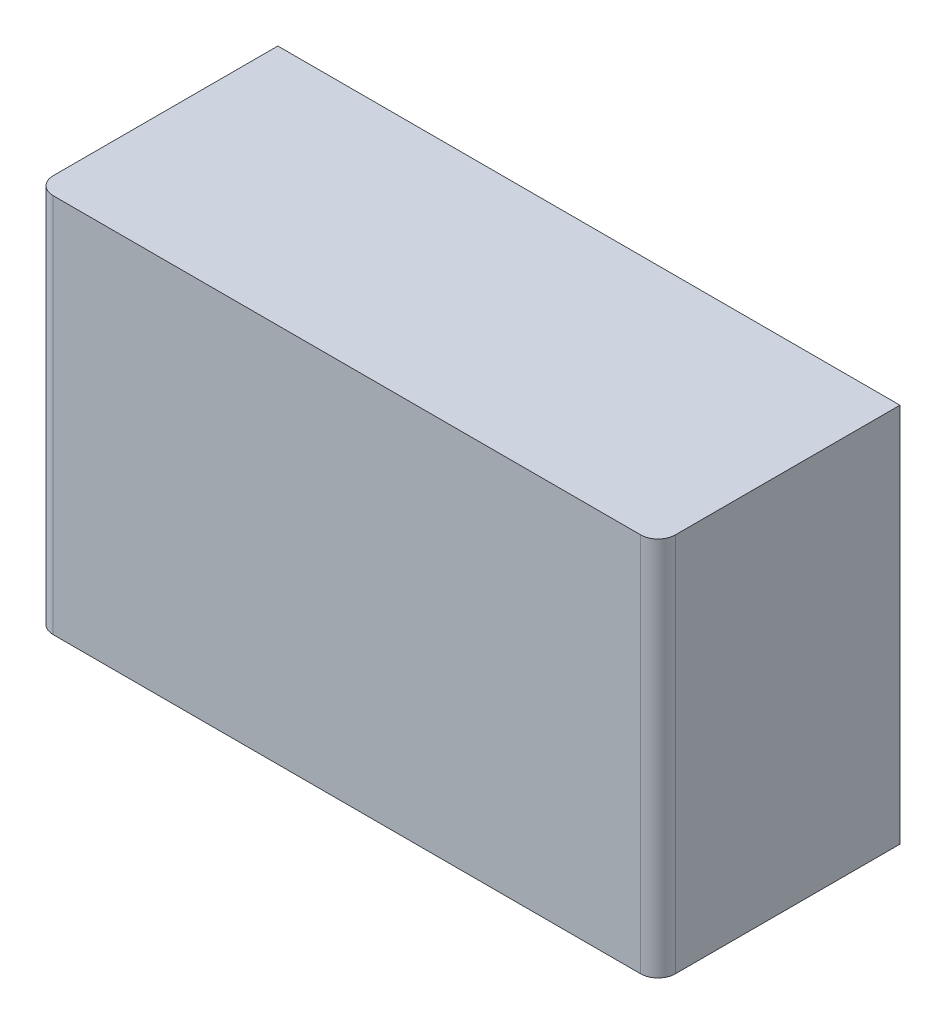
from build123d import *

# Parameters (mm, degrees)
SKETCH1_W           = 914.4
SKETCH1_H           = 355.6
BOSS_EXTRUDE1_DEPTH = 558.8
FILLET1_R           = 25.4


with BuildPart() as part:
    # Sketch1 → Boss-Extrude1 (new body)
    with BuildSketch(Plane(origin=(0, 0, 0), x_dir=(1, 0, 0), z_dir=(0, 1, 0))):
        Rectangle(SKETCH1_W, SKETCH1_H)
    extrude(amount=BOSS_EXTRUDE1_DEPTH)

    # Fillet1
    fillet1_edges = [part.edges().sort_by_distance(p)[0] for p in [
        (457.2, 279.4, 177.8),
        (-457.2, 279.4, 177.8),
    ]]
    fillet(fillet1_edges, radius=FILLET1_R)


solid = part.part
